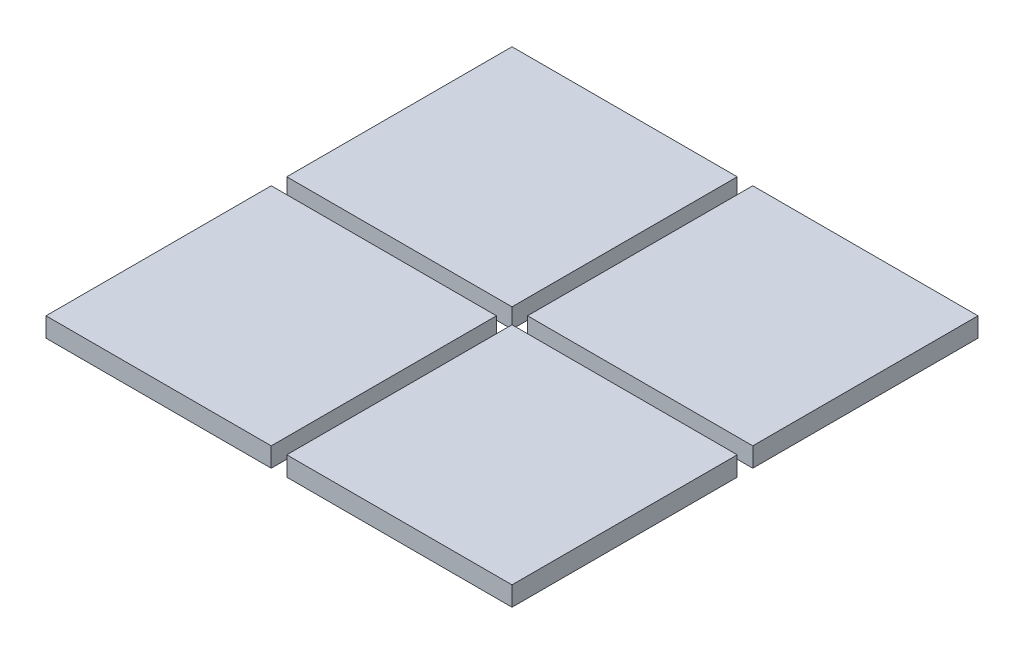
from build123d import *

# Parameters (mm, degrees)
SKETCH_3_W        = 5.8
SKETCH_3_H        = 5.8
EXTRUDE_1_DEPTH   = 0.5
EXTRUDE_1_2_DEPTH = 0.5
EXTRUDE_1_3_DEPTH = 0.5
EXTRUDE_1_4_DEPTH = 0.5
MOVE_BODY_2_ANGLE = 90


with BuildPart() as part:
    # 草图3 → 凸台-拉伸1 (new body)
    with BuildSketch(Plane(origin=(0, 0, 0), x_dir=(0, 0, -1), z_dir=(1, 0, 0))):
        with Locations((3.1, 3.1)):
            Rectangle(SKETCH_3_W, SKETCH_3_H)
    extrude(amount=EXTRUDE_1_DEPTH)


with BuildPart() as body_2:
    # 草图3 → Extrude 1 2 (new body)
    with BuildSketch(Plane(origin=(0, 0, 0), x_dir=(0, 0, -1), z_dir=(1, 0, 0))):
        with Locations((-3.1, -3.1)):
            Rectangle(SKETCH_3_W, SKETCH_3_H)
    extrude(amount=EXTRUDE_1_2_DEPTH)


with BuildPart() as body_3:
    # 草图3 → Extrude 1 3 (new body)
    with BuildSketch(Plane(origin=(0, 0, 0), x_dir=(0, 0, -1), z_dir=(1, 0, 0))):
        with Locations((3.1, -3.1)):
            Rectangle(SKETCH_3_W, SKETCH_3_H)
    extrude(amount=EXTRUDE_1_3_DEPTH)


with BuildPart() as body_4:
    # 草图3 → Extrude 1 4 (new body)
    with BuildSketch(Plane(origin=(0, 0, 0), x_dir=(0, 0, -1), z_dir=(1, 0, 0))):
        with Locations((-3.1, 3.1)):
            Rectangle(SKETCH_3_W, SKETCH_3_H)
    extrude(amount=EXTRUDE_1_4_DEPTH)


with BuildPart() as body_2_1:
    # Move Body 2: moved
    add(body_2.part.rotate(Axis((0, 0, 0), (0, 0, 1)), MOVE_BODY_2_ANGLE))


with BuildPart() as body_4_1:
    # Move Body 2: moved
    add(body_4.part.rotate(Axis((0, 0, 0), (0, 0, 1)), MOVE_BODY_2_ANGLE))


with BuildPart() as part_1:
    # Move Body 2: moved
    add(part.part.rotate(Axis((0, 0, 0), (0, 0, 1)), MOVE_BODY_2_ANGLE))


with BuildPart() as body_3_1:
    # Move Body 2: moved
    add(body_3.part.rotate(Axis((0, 0, 0), (0, 0, 1)), MOVE_BODY_2_ANGLE))


solid = Compound([body_2_1.part, body_4_1.part, part_1.part, body_3_1.part])
